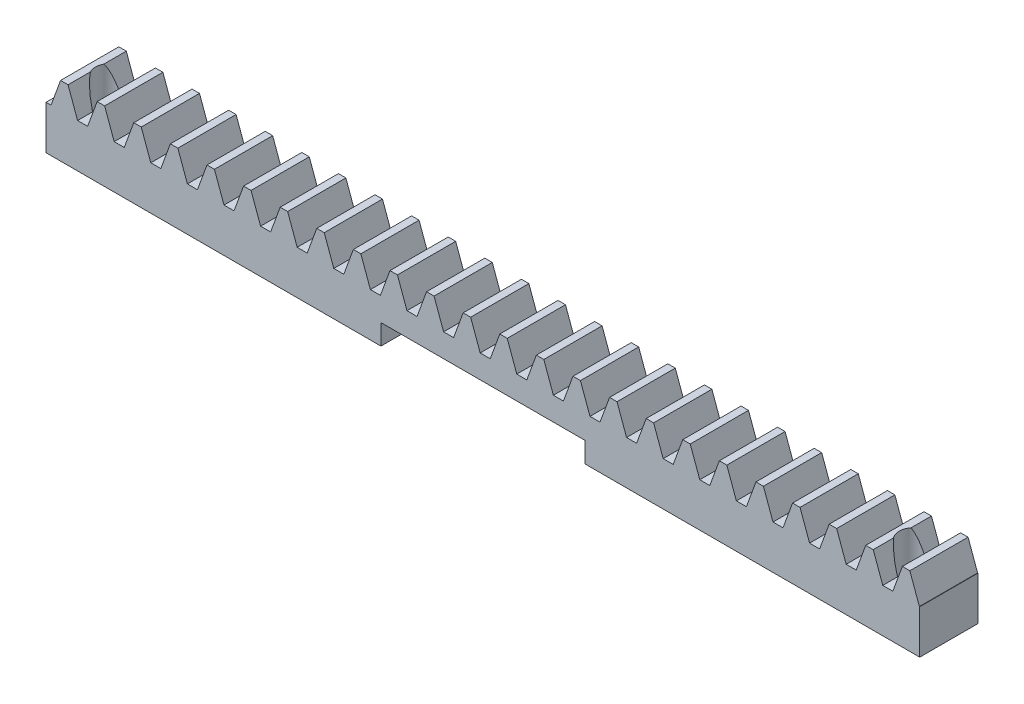
from build123d import *

# Parameters (mm, degrees)
BLANKSKE_W         = 150
BLANKSKE_H         = 12
BLANK_DEPTH        = 10
TOOTHCUTSIM_DEPTH  = 151.811140172
TEETHCUTS_COUNT    = 25
TEETHCUTS_PITCH    = 6.2831853
SKETCH1_W          = 35
SKETCH1_H          = 10
CUT_EXTRUDE1_DEPTH = 3.5
CUT_EXTRUDE2_REACH = 152.811
SKETCH2_R          = 2.5


with BuildPart() as part:
    # BlankSke → Blank (new body)
    with BuildSketch(Plane.XY):
        with Locations((75, 6)):
            Rectangle(BLANKSKE_W, BLANKSKE_H)
    extrude(amount=-BLANK_DEPTH)

    # TooCutSkeSim → ToothCutSim (cut, through all)
    with BuildSketch(Plane.XY):
        Polygon((0.861870739, 7.5), (-0.861870739, 7.5), (-2.508981637, 12.0254), (2.508981637, 12.0254), align=None)
    toothcutsim = extrude(amount=-TOOTHCUTSIM_DEPTH, mode=Mode.SUBTRACT)

    # TeethCuts: ToothCutSim ×25
    with Locations(*[(i * TEETHCUTS_PITCH, 0, 0) for i in range(1, TEETHCUTS_COUNT)]):
        add(toothcutsim, mode=Mode.SUBTRACT)

    # Sketch1 → Cut-Extrude1 (cut)
    with BuildSketch(Plane.XZ):
        with Locations((75, -5)):
            Rectangle(SKETCH1_W, SKETCH1_H)
    extrude(amount=-CUT_EXTRUDE1_DEPTH, mode=Mode.SUBTRACT)

    # Cut-Extrude2: up to this face of the body (flat: up to its plane)
    cut_extrude2_end = Plane(part.part.faces().sort_by_distance((141.37166925, 12, -5))[0])
    # Sketch2 → Cut-Extrude2 (cut, up to the picked face)
    with BuildSketch(Plane.XZ, mode=Mode.PRIVATE) as cut_extrude2_sk1:
        with Locations(Location((6, -5, 0), (0, 0, 270))):
            Circle(SKETCH2_R)
    cut_extrude2_tool1 = split(extrude(cut_extrude2_sk1.sketch, amount=-CUT_EXTRUDE2_REACH, mode=Mode.PRIVATE), bisect_by=cut_extrude2_end, keep=Keep.BOTH, mode=Mode.PRIVATE)
    # Sketch2 → Cut-Extrude2 (cut, up to the picked face)
    with BuildSketch(Plane.XZ, mode=Mode.PRIVATE) as cut_extrude2_sk2:
        with Locations(Location((144, -5, 0), (0, 0, 261.984352652))):
            Circle(SKETCH2_R)
    cut_extrude2_tool2 = split(extrude(cut_extrude2_sk2.sketch, amount=-CUT_EXTRUDE2_REACH, mode=Mode.PRIVATE), bisect_by=cut_extrude2_end, keep=Keep.BOTH, mode=Mode.PRIVATE)
    add(cut_extrude2_tool1.solids().sort_by(Axis((6, 0, -5), (0, 1, 0)))[0], mode=Mode.SUBTRACT)
    add(cut_extrude2_tool2.solids().sort_by(Axis((144, 0, -5), (0, 1, 0)))[0], mode=Mode.SUBTRACT)


solid = part.part
